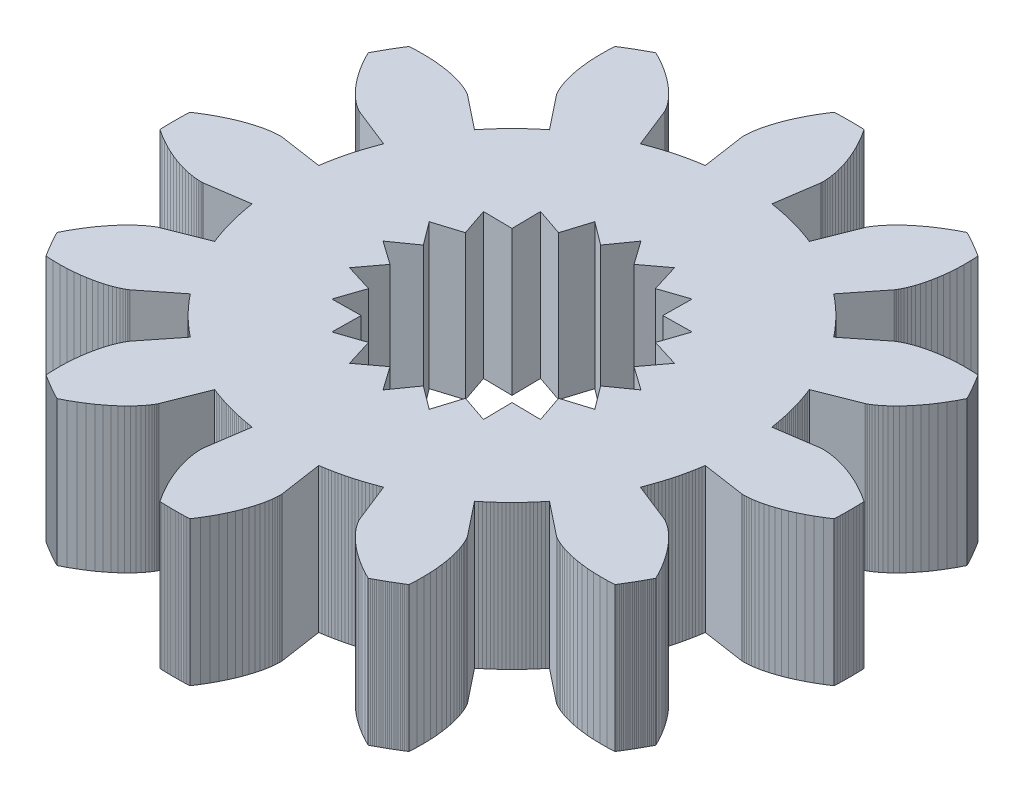
from build123d import *

# Parameters (mm, degrees)
BOSS_EXTRUDE1_DEPTH = 3
CUT_EXTRUDE1_DEPTH  = 4


with BuildPart() as part:
    # Sketch1 → Boss-Extrude1 (new body)
    with BuildSketch(Plane(origin=(0, 0, 0), x_dir=(1, 0, 0), z_dir=(0, 1, 0))):
        Polygon((4.699599664, -0.690118107), (5.578331526, -0.819156496), (5.582528971, -0.819662562), (5.595165866, -0.820746445), (5.616280616, -0.821754286), (5.645873619, -0.822030608), (5.683907215, -0.820920281), (5.730305731, -0.817770484), (5.784955625, -0.811932668), (5.847705722, -0.802764505), (5.918367541, -0.78963183), (5.996715725, -0.771910566), (6.082488554, -0.748988618), (6.175388552, -0.720267756), (6.275083192, -0.685165456), (6.381205679, -0.643116716), (6.493355831, -0.593575823), (6.611101035, -0.536018093), (6.733977296, -0.469941547), (6.861490364, -0.394868552), (6.993116937, -0.310347402), (6.994489556, -0.277697412), (6.995709737, -0.245041371), (6.996777454, -0.212379988), (6.997692683, -0.179713978), (6.998455404, -0.14704405), (6.999065601, -0.114370918), (6.999523261, -0.081695293), (6.999828373, -0.049017888), (6.99998093, -0.016339415), (6.99998093, 0.016339415), (6.999828373, 0.049017888), (6.999523261, 0.081695293), (6.999065601, 0.114370918), (6.998455404, 0.14704405), (6.997692683, 0.179713978), (6.996777454, 0.212379988), (6.995709737, 0.245041371), (6.994489556, 0.277697412), (6.993116937, 0.310347402), (6.861490364, 0.394868552), (6.733977296, 0.469941547), (6.611101035, 0.536018093), (6.493355831, 0.593575823), (6.381205679, 0.643116716), (6.275083192, 0.685165456), (6.175388552, 0.720267756), (6.082488554, 0.748988618), (5.996715725, 0.771910566), (5.918367541, 0.78963183), (5.847705722, 0.802764505), (5.784955625, 0.811932668), (5.730305731, 0.817770484), (5.683907215, 0.820920281), (5.645873619, 0.822030608), (5.616280616, 0.821754286), (5.595165866, 0.820746445), (5.582528971, 0.819662562), (5.578331526, 0.819156496), (4.699599664, 0.690118107), (4.690823193, 0.747447504), (4.6813474, 0.80466547), (4.671173698, 0.861763473), (4.660303603, 0.918733002), (4.648738736, 0.975565563), (4.63648082, 1.032252685), (4.623531684, 1.088785914), (4.609893258, 1.145156825), (4.595567574, 1.201357011), (4.58055677, 1.257378096), (4.564863082, 1.313211727), (4.548488851, 1.368849581), (4.531436517, 1.424283362), (4.513708622, 1.479504807), (4.49530781, 1.534505682), (4.476236824, 1.589277789), (4.456498507, 1.643812962), (4.436095802, 1.69810307), (4.41503175, 1.752140019), (5.24055506, 2.079755427), (5.244443187, 2.081415885), (5.255929001, 2.086795662), (5.274718831, 2.096480221), (5.300485285, 2.111037421), (5.332868181, 2.13101579), (5.371475576, 2.156942852), (5.415884865, 2.189323496), (5.465643961, 2.228638407), (5.520272555, 2.275342546), (5.57926344, 2.329863703), (5.642083915, 2.392601107), (5.708177242, 2.463924102), (5.776964183, 2.544170905), (5.847844583, 2.633647426), (5.920199017, 2.732626174), (5.99339049, 2.841345233), (6.066766181, 2.960007331), (6.139659239, 3.088778985), (6.21139062, 3.227789734), (6.196254348, 3.256751764), (6.180983035, 3.285642817), (6.165577014, 3.314462262), (6.15003662, 3.343209471), (6.134362193, 3.371883819), (6.118554073, 3.40048468), (6.102612605, 3.429011431), (6.086538137, 3.45746345), (6.070331019, 3.485840117), (6.053991604, 3.514140813), (6.037520249, 3.542364923), (6.020917312, 3.57051183), (6.004183155, 3.598580921), (5.987318142, 3.626571585), (5.970322643, 3.654483212), (5.953197026, 3.682315192), (5.935941665, 3.71006692), (5.918556936, 3.737737792), (5.901043218, 3.765327202), (5.744790687, 3.772711379), (5.596824634, 3.773969966), (5.457372397, 3.769755803), (5.326623194, 3.760729657), (5.204727867, 3.747558253), (5.091798727, 3.730912287), (4.987909486, 3.71146445), (4.893095297, 3.689887447), (4.807352875, 3.666852022), (4.730640724, 3.643024995), (4.662879456, 3.619067315), (4.603952197, 3.595632129), (4.553705092, 3.573362879), (4.5119479, 3.552891425), (4.478454677, 3.534836199), (4.452964546, 3.519800395), (4.435182556, 3.508370204), (4.424780626, 3.501113087), (4.421398564, 3.498576098), (3.724913643, 2.947459644), (3.688648298, 2.992720123), (3.651833038, 3.037534438), (3.614473351, 3.081895909), (3.576574808, 3.12579792), (3.538143059, 3.169233929), (3.499183832, 3.212197458), (3.459702936, 3.254682103), (3.419706258, 3.29668153), (3.379199759, 3.338189478), (3.338189478, 3.379199759), (3.29668153, 3.419706258), (3.254682103, 3.459702936), (3.212197458, 3.499183832), (3.169233929, 3.538143059), (3.12579792, 3.576574808), (3.081895909, 3.614473351), (3.037534438, 3.651833038), (2.992720123, 3.688648298), (2.947459644, 3.724913643), (3.498576098, 4.421398564), (3.501113087, 4.424780626), (3.508370204, 4.435182556), (3.519800395, 4.452964546), (3.534836199, 4.478454677), (3.552891425, 4.5119479), (3.573362879, 4.553705092), (3.595632129, 4.603952197), (3.619067315, 4.662879456), (3.643024995, 4.730640724), (3.666852022, 4.807352875), (3.689887447, 4.893095297), (3.71146445, 4.987909486), (3.730912287, 5.091798727), (3.747558253, 5.204727867), (3.760729657, 5.326623194), (3.769755803, 5.457372397), (3.773969966, 5.596824634), (3.772711379, 5.744790687), (3.765327202, 5.901043218), (3.737737792, 5.918556936), (3.71006692, 5.935941665), (3.682315192, 5.953197026), (3.654483212, 5.970322643), (3.626571585, 5.987318142), (3.598580921, 6.004183155), (3.57051183, 6.020917312), (3.542364923, 6.037520249), (3.514140813, 6.053991604), (3.485840117, 6.070331019), (3.45746345, 6.086538137), (3.429011431, 6.102612605), (3.40048468, 6.118554073), (3.371883819, 6.134362193), (3.343209471, 6.15003662), (3.314462262, 6.165577014), (3.285642817, 6.180983035), (3.256751764, 6.196254348), (3.227789734, 6.21139062), (3.088778985, 6.139659239), (2.960007331, 6.066766181), (2.841345233, 5.99339049), (2.732626174, 5.920199017), (2.633647426, 5.847844583), (2.544170905, 5.776964183), (2.463924102, 5.708177242), (2.392601107, 5.642083915), (2.329863703, 5.57926344), (2.275342546, 5.520272555), (2.228638407, 5.465643961), (2.189323496, 5.415884865), (2.156942852, 5.371475576), (2.13101579, 5.332868181), (2.111037421, 5.300485285), (2.096480221, 5.274718831), (2.086795662, 5.255929001), (2.081415885, 5.244443187), (2.079755427, 5.24055506), (1.752140019, 4.41503175), (1.69810307, 4.436095802), (1.643812962, 4.456498507), (1.589277789, 4.476236824), (1.534505682, 4.49530781), (1.479504807, 4.513708622), (1.424283362, 4.531436517), (1.368849581, 4.548488851), (1.313211727, 4.564863082), (1.257378096, 4.58055677), (1.201357011, 4.595567574), (1.145156825, 4.609893258), (1.088785914, 4.623531684), (1.032252685, 4.63648082), (0.975565563, 4.648738736), (0.918733002, 4.660303603), (0.861763473, 4.671173698), (0.80466547, 4.6813474), (0.747447504, 4.690823193), (0.690118107, 4.699599664), (0.819156496, 5.578331526), (0.819662562, 5.582528971), (0.820746445, 5.595165866), (0.821754286, 5.616280616), (0.822030608, 5.645873619), (0.820920281, 5.683907215), (0.817770484, 5.730305731), (0.811932668, 5.784955625), (0.802764505, 5.847705722), (0.78963183, 5.918367541), (0.771910566, 5.996715725), (0.748988618, 6.082488554), (0.720267756, 6.175388552), (0.685165456, 6.275083192), (0.643116716, 6.381205679), (0.593575823, 6.493355831), (0.536018093, 6.611101035), (0.469941547, 6.733977296), (0.394868552, 6.861490364), (0.310347402, 6.993116937), (0.277697412, 6.994489556), (0.245041371, 6.995709737), (0.212379988, 6.996777454), (0.179713978, 6.997692683), (0.14704405, 6.998455404), (0.114370918, 6.999065601), (0.081695293, 6.999523261), (0.049017888, 6.999828373), (0.016339415, 6.99998093), (-0.016339415, 6.99998093), (-0.049017888, 6.999828373), (-0.081695293, 6.999523261), (-0.114370918, 6.999065601), (-0.14704405, 6.998455404), (-0.179713978, 6.997692683), (-0.212379988, 6.996777454), (-0.245041371, 6.995709737), (-0.277697412, 6.994489556), (-0.310347402, 6.993116937), (-0.394868552, 6.861490364), (-0.469941547, 6.733977296), (-0.536018093, 6.611101035), (-0.593575823, 6.493355831), (-0.643116716, 6.381205679), (-0.685165456, 6.275083192), (-0.720267756, 6.175388552), (-0.748988618, 6.082488554), (-0.771910566, 5.996715725), (-0.78963183, 5.918367541), (-0.802764505, 5.847705722), (-0.811932668, 5.784955625), (-0.817770484, 5.730305731), (-0.820920281, 5.683907215), (-0.822030608, 5.645873619), (-0.821754286, 5.616280616), (-0.820746445, 5.595165866), (-0.819662562, 5.582528971), (-0.819156496, 5.578331526), (-0.690118107, 4.699599664), (-0.747447504, 4.690823193), (-0.80466547, 4.6813474), (-0.861763473, 4.671173698), (-0.918733002, 4.660303603), (-0.975565563, 4.648738736), (-1.032252685, 4.63648082), (-1.088785914, 4.623531684), (-1.145156825, 4.609893258), (-1.201357011, 4.595567574), (-1.257378096, 4.58055677), (-1.313211727, 4.564863082), (-1.368849581, 4.548488851), (-1.424283362, 4.531436517), (-1.479504807, 4.513708622), (-1.534505682, 4.49530781), (-1.589277789, 4.476236824), (-1.643812962, 4.456498507), (-1.69810307, 4.436095802), (-1.752140019, 4.41503175), (-2.079755427, 5.24055506), (-2.081415885, 5.244443187), (-2.086795662, 5.255929001), (-2.096480221, 5.274718831), (-2.111037421, 5.300485285), (-2.13101579, 5.332868181), (-2.156942852, 5.371475576), (-2.189323496, 5.415884865), (-2.228638407, 5.465643961), (-2.275342546, 5.520272555), (-2.329863703, 5.57926344), (-2.392601107, 5.642083915), (-2.463924102, 5.708177242), (-2.544170905, 5.776964183), (-2.633647426, 5.847844583), (-2.732626174, 5.920199017), (-2.841345233, 5.99339049), (-2.960007331, 6.066766181), (-3.088778985, 6.139659239), (-3.227789734, 6.21139062), (-3.256751764, 6.196254348), (-3.285642817, 6.180983035), (-3.314462262, 6.165577014), (-3.343209471, 6.15003662), (-3.371883819, 6.134362193), (-3.40048468, 6.118554073), (-3.429011431, 6.102612605), (-3.45746345, 6.086538137), (-3.485840117, 6.070331019), (-3.514140813, 6.053991604), (-3.542364923, 6.037520249), (-3.57051183, 6.020917312), (-3.598580921, 6.004183155), (-3.626571585, 5.987318142), (-3.654483212, 5.970322643), (-3.682315192, 5.953197026), (-3.71006692, 5.935941665), (-3.737737792, 5.918556936), (-3.765327202, 5.901043218), (-3.772711379, 5.744790687), (-3.773969966, 5.596824634), (-3.769755803, 5.457372397), (-3.760729657, 5.326623194), (-3.747558253, 5.204727867), (-3.730912287, 5.091798727), (-3.71146445, 4.987909486), (-3.689887447, 4.893095297), (-3.666852022, 4.807352875), (-3.643024995, 4.730640724), (-3.619067315, 4.662879456), (-3.595632129, 4.603952197), (-3.573362879, 4.553705092), (-3.552891425, 4.5119479), (-3.534836199, 4.478454677), (-3.519800395, 4.452964546), (-3.508370204, 4.435182556), (-3.501113087, 4.424780626), (-3.498576098, 4.421398564), (-2.947459644, 3.724913643), (-2.992720123, 3.688648298), (-3.037534438, 3.651833038), (-3.081895909, 3.614473351), (-3.12579792, 3.576574808), (-3.169233929, 3.538143059), (-3.212197458, 3.499183832), (-3.254682103, 3.459702936), (-3.29668153, 3.419706258), (-3.338189478, 3.379199759), (-3.379199759, 3.338189478), (-3.419706258, 3.29668153), (-3.459702936, 3.254682103), (-3.499183832, 3.212197458), (-3.538143059, 3.169233929), (-3.576574808, 3.12579792), (-3.614473351, 3.081895909), (-3.651833038, 3.037534438), (-3.688648298, 2.992720123), (-3.724913643, 2.947459644), (-4.421398564, 3.498576098), (-4.424780626, 3.501113087), (-4.435182556, 3.508370204), (-4.452964546, 3.519800395), (-4.478454677, 3.534836199), (-4.5119479, 3.552891425), (-4.553705092, 3.573362879), (-4.603952197, 3.595632129), (-4.662879456, 3.619067315), (-4.730640724, 3.643024995), (-4.807352875, 3.666852022), (-4.893095297, 3.689887447), (-4.987909486, 3.71146445), (-5.091798727, 3.730912287), (-5.204727867, 3.747558253), (-5.326623194, 3.760729657), (-5.457372397, 3.769755803), (-5.596824634, 3.773969966), (-5.744790687, 3.772711379), (-5.901043218, 3.765327202), (-5.918556936, 3.737737792), (-5.935941665, 3.71006692), (-5.953197026, 3.682315192), (-5.970322643, 3.654483212), (-5.987318142, 3.626571585), (-6.004183155, 3.598580921), (-6.020917312, 3.57051183), (-6.037520249, 3.542364923), (-6.053991604, 3.514140813), (-6.070331019, 3.485840117), (-6.086538137, 3.45746345), (-6.102612605, 3.429011431), (-6.118554073, 3.40048468), (-6.134362193, 3.371883819), (-6.15003662, 3.343209471), (-6.165577014, 3.314462262), (-6.180983035, 3.285642817), (-6.196254348, 3.256751764), (-6.21139062, 3.227789734), (-6.139659239, 3.088778985), (-6.066766181, 2.960007331), (-5.99339049, 2.841345233), (-5.920199017, 2.732626174), (-5.847844583, 2.633647426), (-5.776964183, 2.544170905), (-5.708177242, 2.463924102), (-5.642083915, 2.392601107), (-5.57926344, 2.329863703), (-5.520272555, 2.275342546), (-5.465643961, 2.228638407), (-5.415884865, 2.189323496), (-5.371475576, 2.156942852), (-5.332868181, 2.13101579), (-5.300485285, 2.111037421), (-5.274718831, 2.096480221), (-5.255929001, 2.086795662), (-5.244443187, 2.081415885), (-5.24055506, 2.079755427), (-4.41503175, 1.752140019), (-4.436095802, 1.69810307), (-4.456498507, 1.643812962), (-4.476236824, 1.589277789), (-4.49530781, 1.534505682), (-4.513708622, 1.479504807), (-4.531436517, 1.424283362), (-4.548488851, 1.368849581), (-4.564863082, 1.313211727), (-4.58055677, 1.257378096), (-4.595567574, 1.201357011), (-4.609893258, 1.145156825), (-4.623531684, 1.088785914), (-4.63648082, 1.032252685), (-4.648738736, 0.975565563), (-4.660303603, 0.918733002), (-4.671173698, 0.861763473), (-4.6813474, 0.80466547), (-4.690823193, 0.747447504), (-4.699599664, 0.690118107), (-5.578331526, 0.819156496), (-5.582528971, 0.819662562), (-5.595165866, 0.820746445), (-5.616280616, 0.821754286), (-5.645873619, 0.822030608), (-5.683907215, 0.820920281), (-5.730305731, 0.817770484), (-5.784955625, 0.811932668), (-5.847705722, 0.802764505), (-5.918367541, 0.78963183), (-5.996715725, 0.771910566), (-6.082488554, 0.748988618), (-6.175388552, 0.720267756), (-6.275083192, 0.685165456), (-6.381205679, 0.643116716), (-6.493355831, 0.593575823), (-6.611101035, 0.536018093), (-6.733977296, 0.469941547), (-6.861490364, 0.394868552), (-6.993116937, 0.310347402), (-6.994489556, 0.277697412), (-6.995709737, 0.245041371), (-6.996777454, 0.212379988), (-6.997692683, 0.179713978), (-6.998455404, 0.14704405), (-6.999065601, 0.114370918), (-6.999523261, 0.081695293), (-6.999828373, 0.049017888), (-6.99998093, 0.016339415), (-6.99998093, -0.016339415), (-6.999828373, -0.049017888), (-6.999523261, -0.081695293), (-6.999065601, -0.114370918), (-6.998455404, -0.14704405), (-6.997692683, -0.179713978), (-6.996777454, -0.212379988), (-6.995709737, -0.245041371), (-6.994489556, -0.277697412), (-6.993116937, -0.310347402), (-6.861490364, -0.394868552), (-6.733977296, -0.469941547), (-6.611101035, -0.536018093), (-6.493355831, -0.593575823), (-6.381205679, -0.643116716), (-6.275083192, -0.685165456), (-6.175388552, -0.720267756), (-6.082488554, -0.748988618), (-5.996715725, -0.771910566), (-5.918367541, -0.78963183), (-5.847705722, -0.802764505), (-5.784955625, -0.811932668), (-5.730305731, -0.817770484), (-5.683907215, -0.820920281), (-5.645873619, -0.822030608), (-5.616280616, -0.821754286), (-5.595165866, -0.820746445), (-5.582528971, -0.819662562), (-5.578331526, -0.819156496), (-4.699599664, -0.690118107), (-4.690823193, -0.747447504), (-4.6813474, -0.80466547), (-4.671173698, -0.861763473), (-4.660303603, -0.918733002), (-4.648738736, -0.975565563), (-4.63648082, -1.032252685), (-4.623531684, -1.088785914), (-4.609893258, -1.145156825), (-4.595567574, -1.201357011), (-4.58055677, -1.257378096), (-4.564863082, -1.313211727), (-4.548488851, -1.368849581), (-4.531436517, -1.424283362), (-4.513708622, -1.479504807), (-4.49530781, -1.534505682), (-4.476236824, -1.589277789), (-4.456498507, -1.643812962), (-4.436095802, -1.69810307), (-4.41503175, -1.752140019), (-5.24055506, -2.079755427), (-5.244443187, -2.081415885), (-5.255929001, -2.086795662), (-5.274718831, -2.096480221), (-5.300485285, -2.111037421), (-5.332868181, -2.13101579), (-5.371475576, -2.156942852), (-5.415884865, -2.189323496), (-5.465643961, -2.228638407), (-5.520272555, -2.275342546), (-5.57926344, -2.329863703), (-5.642083915, -2.392601107), (-5.708177242, -2.463924102), (-5.776964183, -2.544170905), (-5.847844583, -2.633647426), (-5.920199017, -2.732626174), (-5.99339049, -2.841345233), (-6.066766181, -2.960007331), (-6.139659239, -3.088778985), (-6.21139062, -3.227789734), (-6.196254348, -3.256751764), (-6.180983035, -3.285642817), (-6.165577014, -3.314462262), (-6.15003662, -3.343209471), (-6.134362193, -3.371883819), (-6.118554073, -3.40048468), (-6.102612605, -3.429011431), (-6.086538137, -3.45746345), (-6.070331019, -3.485840117), (-6.053991604, -3.514140813), (-6.037520249, -3.542364923), (-6.020917312, -3.57051183), (-6.004183155, -3.598580921), (-5.987318142, -3.626571585), (-5.970322643, -3.654483212), (-5.953197026, -3.682315192), (-5.935941665, -3.71006692), (-5.918556936, -3.737737792), (-5.901043218, -3.765327202), (-5.744790687, -3.772711379), (-5.596824634, -3.773969966), (-5.457372397, -3.769755803), (-5.326623194, -3.760729657), (-5.204727867, -3.747558253), (-5.091798727, -3.730912287), (-4.987909486, -3.71146445), (-4.893095297, -3.689887447), (-4.807352875, -3.666852022), (-4.730640724, -3.643024995), (-4.662879456, -3.619067315), (-4.603952197, -3.595632129), (-4.553705092, -3.573362879), (-4.5119479, -3.552891425), (-4.478454677, -3.534836199), (-4.452964546, -3.519800395), (-4.435182556, -3.508370204), (-4.424780626, -3.501113087), (-4.421398564, -3.498576098), (-3.724913643, -2.947459644), (-3.688648298, -2.992720123), (-3.651833038, -3.037534438), (-3.614473351, -3.081895909), (-3.576574808, -3.12579792), (-3.538143059, -3.169233929), (-3.499183832, -3.212197458), (-3.459702936, -3.254682103), (-3.419706258, -3.29668153), (-3.379199759, -3.338189478), (-3.338189478, -3.379199759), (-3.29668153, -3.419706258), (-3.254682103, -3.459702936), (-3.212197458, -3.499183832), (-3.169233929, -3.538143059), (-3.12579792, -3.576574808), (-3.081895909, -3.614473351), (-3.037534438, -3.651833038), (-2.992720123, -3.688648298), (-2.947459644, -3.724913643), (-3.498576098, -4.421398564), (-3.501113087, -4.424780626), (-3.508370204, -4.435182556), (-3.519800395, -4.452964546), (-3.534836199, -4.478454677), (-3.552891425, -4.5119479), (-3.573362879, -4.553705092), (-3.595632129, -4.603952197), (-3.619067315, -4.662879456), (-3.643024995, -4.730640724), (-3.666852022, -4.807352875), (-3.689887447, -4.893095297), (-3.71146445, -4.987909486), (-3.730912287, -5.091798727), (-3.747558253, -5.204727867), (-3.760729657, -5.326623194), (-3.769755803, -5.457372397), (-3.773969966, -5.596824634), (-3.772711379, -5.744790687), (-3.765327202, -5.901043218), (-3.737737792, -5.918556936), (-3.71006692, -5.935941665), (-3.682315192, -5.953197026), (-3.654483212, -5.970322643), (-3.626571585, -5.987318142), (-3.598580921, -6.004183155), (-3.57051183, -6.020917312), (-3.542364923, -6.037520249), (-3.514140813, -6.053991604), (-3.485840117, -6.070331019), (-3.45746345, -6.086538137), (-3.429011431, -6.102612605), (-3.40048468, -6.118554073), (-3.371883819, -6.134362193), (-3.343209471, -6.15003662), (-3.314462262, -6.165577014), (-3.285642817, -6.180983035), (-3.256751764, -6.196254348), (-3.227789734, -6.21139062), (-3.088778985, -6.139659239), (-2.960007331, -6.066766181), (-2.841345233, -5.99339049), (-2.732626174, -5.920199017), (-2.633647426, -5.847844583), (-2.544170905, -5.776964183), (-2.463924102, -5.708177242), (-2.392601107, -5.642083915), (-2.329863703, -5.57926344), (-2.275342546, -5.520272555), (-2.228638407, -5.465643961), (-2.189323496, -5.415884865), (-2.156942852, -5.371475576), (-2.13101579, -5.332868181), (-2.111037421, -5.300485285), (-2.096480221, -5.274718831), (-2.086795662, -5.255929001), (-2.081415885, -5.244443187), (-2.079755427, -5.24055506), (-1.752140019, -4.41503175), (-1.69810307, -4.436095802), (-1.643812962, -4.456498507), (-1.589277789, -4.476236824), (-1.534505682, -4.49530781), (-1.479504807, -4.513708622), (-1.424283362, -4.531436517), (-1.368849581, -4.548488851), (-1.313211727, -4.564863082), (-1.257378096, -4.58055677), (-1.201357011, -4.595567574), (-1.145156825, -4.609893258), (-1.088785914, -4.623531684), (-1.032252685, -4.63648082), (-0.975565563, -4.648738736), (-0.918733002, -4.660303603), (-0.861763473, -4.671173698), (-0.80466547, -4.6813474), (-0.747447504, -4.690823193), (-0.690118107, -4.699599664), (-0.819156496, -5.578331526), (-0.819662562, -5.582528971), (-0.820746445, -5.595165866), (-0.821754286, -5.616280616), (-0.822030608, -5.645873619), (-0.820920281, -5.683907215), (-0.817770484, -5.730305731), (-0.811932668, -5.784955625), (-0.802764505, -5.847705722), (-0.78963183, -5.918367541), (-0.771910566, -5.996715725), (-0.748988618, -6.082488554), (-0.720267756, -6.175388552), (-0.685165456, -6.275083192), (-0.643116716, -6.381205679), (-0.593575823, -6.493355831), (-0.536018093, -6.611101035), (-0.469941547, -6.733977296), (-0.394868552, -6.861490364), (-0.310347402, -6.993116937), (-0.277697412, -6.994489556), (-0.245041371, -6.995709737), (-0.212379988, -6.996777454), (-0.179713978, -6.997692683), (-0.14704405, -6.998455404), (-0.114370918, -6.999065601), (-0.081695293, -6.999523261), (-0.049017888, -6.999828373), (-0.016339415, -6.99998093), (0.016339415, -6.99998093), (0.049017888, -6.999828373), (0.081695293, -6.999523261), (0.114370918, -6.999065601), (0.14704405, -6.998455404), (0.179713978, -6.997692683), (0.212379988, -6.996777454), (0.245041371, -6.995709737), (0.277697412, -6.994489556), (0.310347402, -6.993116937), (0.394868552, -6.861490364), (0.469941547, -6.733977296), (0.536018093, -6.611101035), (0.593575823, -6.493355831), (0.643116716, -6.381205679), (0.685165456, -6.275083192), (0.720267756, -6.175388552), (0.748988618, -6.082488554), (0.771910566, -5.996715725), (0.78963183, -5.918367541), (0.802764505, -5.847705722), (0.811932668, -5.784955625), (0.817770484, -5.730305731), (0.820920281, -5.683907215), (0.822030608, -5.645873619), (0.821754286, -5.616280616), (0.820746445, -5.595165866), (0.819662562, -5.582528971), (0.819156496, -5.578331526), (0.690118107, -4.699599664), (0.747447504, -4.690823193), (0.80466547, -4.6813474), (0.861763473, -4.671173698), (0.918733002, -4.660303603), (0.975565563, -4.648738736), (1.032252685, -4.63648082), (1.088785914, -4.623531684), (1.145156825, -4.609893258), (1.201357011, -4.595567574), (1.257378096, -4.58055677), (1.313211727, -4.564863082), (1.368849581, -4.548488851), (1.424283362, -4.531436517), (1.479504807, -4.513708622), (1.534505682, -4.49530781), (1.589277789, -4.476236824), (1.643812962, -4.456498507), (1.69810307, -4.436095802), (1.752140019, -4.41503175), (2.079755427, -5.24055506), (2.081415885, -5.244443187), (2.086795662, -5.255929001), (2.096480221, -5.274718831), (2.111037421, -5.300485285), (2.13101579, -5.332868181), (2.156942852, -5.371475576), (2.189323496, -5.415884865), (2.228638407, -5.465643961), (2.275342546, -5.520272555), (2.329863703, -5.57926344), (2.392601107, -5.642083915), (2.463924102, -5.708177242), (2.544170905, -5.776964183), (2.633647426, -5.847844583), (2.732626174, -5.920199017), (2.841345233, -5.99339049), (2.960007331, -6.066766181), (3.088778985, -6.139659239), (3.227789734, -6.21139062), (3.256751764, -6.196254348), (3.285642817, -6.180983035), (3.314462262, -6.165577014), (3.343209471, -6.15003662), (3.371883819, -6.134362193), (3.40048468, -6.118554073), (3.429011431, -6.102612605), (3.45746345, -6.086538137), (3.485840117, -6.070331019), (3.514140813, -6.053991604), (3.542364923, -6.037520249), (3.57051183, -6.020917312), (3.598580921, -6.004183155), (3.626571585, -5.987318142), (3.654483212, -5.970322643), (3.682315192, -5.953197026), (3.71006692, -5.935941665), (3.737737792, -5.918556936), (3.765327202, -5.901043218), (3.772711379, -5.744790687), (3.773969966, -5.596824634), (3.769755803, -5.457372397), (3.760729657, -5.326623194), (3.747558253, -5.204727867), (3.730912287, -5.091798727), (3.71146445, -4.987909486), (3.689887447, -4.893095297), (3.666852022, -4.807352875), (3.643024995, -4.730640724), (3.619067315, -4.662879456), (3.595632129, -4.603952197), (3.573362879, -4.553705092), (3.552891425, -4.5119479), (3.534836199, -4.478454677), (3.519800395, -4.452964546), (3.508370204, -4.435182556), (3.501113087, -4.424780626), (3.498576098, -4.421398564), (2.947459644, -3.724913643), (2.992720123, -3.688648298), (3.037534438, -3.651833038), (3.081895909, -3.614473351), (3.12579792, -3.576574808), (3.169233929, -3.538143059), (3.212197458, -3.499183832), (3.254682103, -3.459702936), (3.29668153, -3.419706258), (3.338189478, -3.379199759), (3.379199759, -3.338189478), (3.419706258, -3.29668153), (3.459702936, -3.254682103), (3.499183832, -3.212197458), (3.538143059, -3.169233929), (3.576574808, -3.12579792), (3.614473351, -3.081895909), (3.651833038, -3.037534438), (3.688648298, -2.992720123), (3.724913643, -2.947459644), (4.421398564, -3.498576098), (4.424780626, -3.501113087), (4.435182556, -3.508370204), (4.452964546, -3.519800395), (4.478454677, -3.534836199), (4.5119479, -3.552891425), (4.553705092, -3.573362879), (4.603952197, -3.595632129), (4.662879456, -3.619067315), (4.730640724, -3.643024995), (4.807352875, -3.666852022), (4.893095297, -3.689887447), (4.987909486, -3.71146445), (5.091798727, -3.730912287), (5.204727867, -3.747558253), (5.326623194, -3.760729657), (5.457372397, -3.769755803), (5.596824634, -3.773969966), (5.744790687, -3.772711379), (5.901043218, -3.765327202), (5.918556936, -3.737737792), (5.935941665, -3.71006692), (5.953197026, -3.682315192), (5.970322643, -3.654483212), (5.987318142, -3.626571585), (6.004183155, -3.598580921), (6.020917312, -3.57051183), (6.037520249, -3.542364923), (6.053991604, -3.514140813), (6.070331019, -3.485840117), (6.086538137, -3.45746345), (6.102612605, -3.429011431), (6.118554073, -3.40048468), (6.134362193, -3.371883819), (6.15003662, -3.343209471), (6.165577014, -3.314462262), (6.180983035, -3.285642817), (6.196254348, -3.256751764), (6.21139062, -3.227789734), (6.139659239, -3.088778985), (6.066766181, -2.960007331), (5.99339049, -2.841345233), (5.920199017, -2.732626174), (5.847844583, -2.633647426), (5.776964183, -2.544170905), (5.708177242, -2.463924102), (5.642083915, -2.392601107), (5.57926344, -2.329863703), (5.520272555, -2.275342546), (5.465643961, -2.228638407), (5.415884865, -2.189323496), (5.371475576, -2.156942852), (5.332868181, -2.13101579), (5.300485285, -2.111037421), (5.274718831, -2.096480221), (5.255929001, -2.086795662), (5.244443187, -2.081415885), (5.24055506, -2.079755427), (4.41503175, -1.752140019), (4.436095802, -1.69810307), (4.456498507, -1.643812962), (4.476236824, -1.589277789), (4.49530781, -1.534505682), (4.513708622, -1.479504807), (4.531436517, -1.424283362), (4.548488851, -1.368849581), (4.564863082, -1.313211727), (4.58055677, -1.257378096), (4.595567574, -1.201357011), (4.609893258, -1.145156825), (4.623531684, -1.088785914), (4.63648082, -1.032252685), (4.648738736, -0.975565563), (4.660303603, -0.918733002), (4.671173698, -0.861763473), (4.6813474, -0.80466547), (4.690823193, -0.747447504), align=None)
    extrude(amount=BOSS_EXTRUDE1_DEPTH)

    # Sketch2 → Cut-Extrude1 (cut, through all)
    with BuildSketch(Plane(origin=(0, 3, 0), x_dir=(1, 0, 0), z_dir=(0, 1, 0))):
        Polygon((-0.34604534, 2.184844287), (0, 2.675), (0.34604534, 2.184844287), (0.82662046, 2.544076181), (1.00426269, 1.970976506), (1.57232555, 2.16412046), (1.564175811, 1.564175811), (2.16412046, 1.57232555), (1.970976506, 1.00426269), (2.544076181, 0.82662046), (2.184844287, 0.34604534), (2.675, 0), (2.184844287, -0.34604534), (2.544076181, -0.82662046), (1.970976506, -1.00426269), (2.16412046, -1.57232555), (1.564175811, -1.564175811), (1.57232555, -2.16412046), (1.00426269, -1.970976506), (0.82662046, -2.544076181), (0.34604534, -2.184844287), (0, -2.675), (-0.34604534, -2.184844287), (-0.82662046, -2.544076181), (-1.00426269, -1.970976506), (-1.57232555, -2.16412046), (-1.564175811, -1.564175811), (-2.16412046, -1.57232555), (-1.970976506, -1.00426269), (-2.544076181, -0.82662046), (-2.184844287, -0.34604534), (-2.675, 0), (-2.184844287, 0.34604534), (-2.544076181, 0.82662046), (-1.970976506, 1.00426269), (-2.16412046, 1.57232555), (-1.564175811, 1.564175811), (-1.57232555, 2.16412046), (-1.00426269, 1.970976506), (-0.82662046, 2.544076181), align=None)
    extrude(amount=-CUT_EXTRUDE1_DEPTH, mode=Mode.SUBTRACT)


solid = part.part
